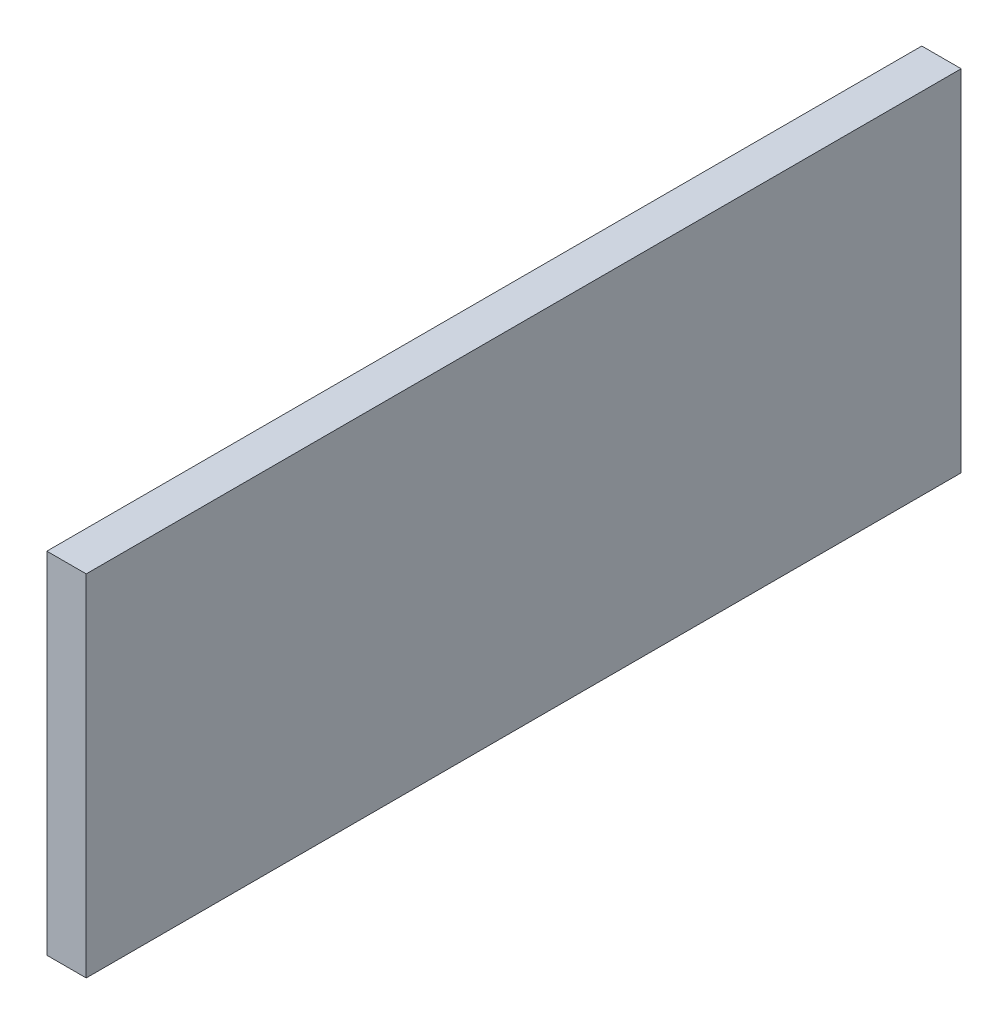
from build123d import *

# Parameters (mm, degrees)
SKETCH1_W           = 400
SKETCH1_H           = 160
BOSS_EXTRUDE1_DEPTH = 18


with BuildPart() as part:
    # Sketch1 → Boss-Extrude1 (new body)
    with BuildSketch(Plane(origin=(0, 0, 0), x_dir=(0, 0, -1), z_dir=(1, 0, 0))):
        with Locations((170.985681999, -72.7464205)):
            Rectangle(SKETCH1_W, SKETCH1_H)
    extrude(amount=BOSS_EXTRUDE1_DEPTH)


solid = part.part
